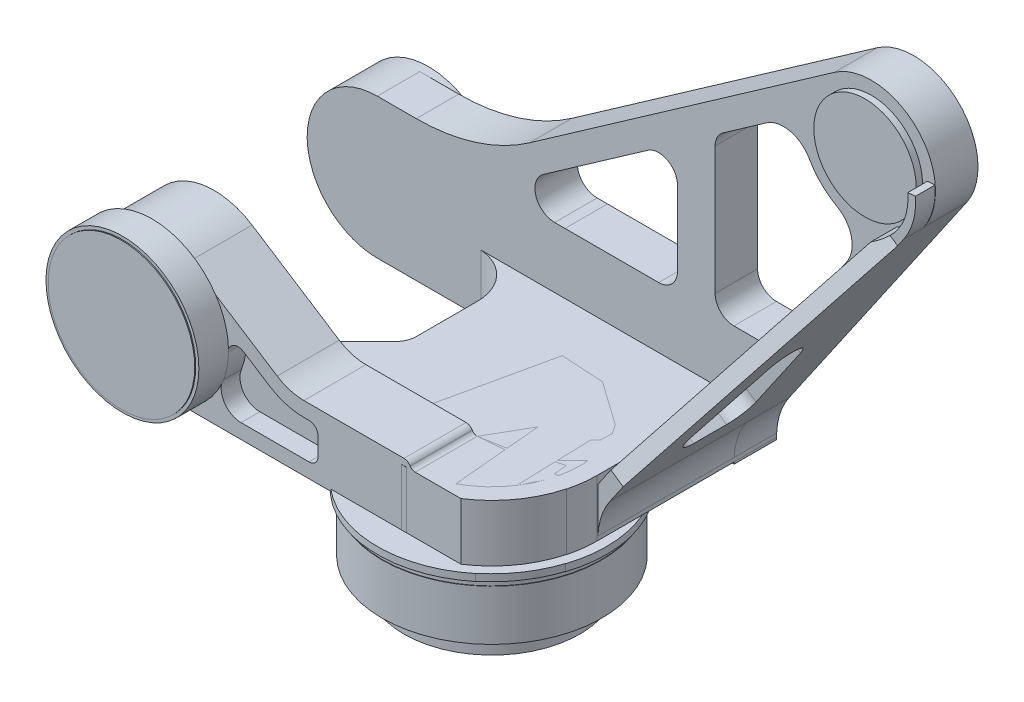
from build123d import *

# Parameters (mm, degrees)
SKETCH3_R               = 80.137
EXTRUDE1_DEPTH          = 6.5
SKETCH4_R               = 79.375
EXTRUDE2_DEPTH          = 13.5
SKETCH5_R               = 88.011
EXTRUDE3_DEPTH          = 5
SKETCH6_R               = 111.252
EXTRUDE4_DEPTH          = 51
SKETCH7_R               = 110.744
EXTRUDE5_DEPTH          = 7
SKETCH8_R               = 115.824
EXTRUDE6_DEPTH          = 7
EXTRUDE7_DEPTH          = 62.838001
CUT_EXTRUDE1_DEPTH      = 57.530765
CUT_EXTRUDE2_DEPTH      = 12.7
CUT_EXTRUDE3_DEPTH      = 19.05
SKETCH18_R              = 77.380878
EXTRUDE13_DEPTH         = 29.999999
SKETCH19_R              = 74.205878
EXTRUDE14_DEPTH         = 1
EXTRUDE15_DEPTH         = 57.530765
EXTRUDE17_START         = -43
EXTRUDE17_DEPTH         = 43
CUT_EXTRUDE4_DEPTH      = 43
EXTRUDE18_DEPTH         = 8.83485
EXTRUDE19_DEPTH         = 137.9365
CUT_EXTRUDE8_DEPTH      = 25.4
CUT_EXTRUDE8_DEPTH_BACK = 25.4
CUT_EXTRUDE9_DEPTH      = 247.851187
SKETCH34_R              = 56.999996
CUT_EXTRUDE10_DEPTH     = 101.6
SKETCH35_R              = 51.839563
EXTRUDE25_DEPTH         = 6.35
SKETCH40_R              = 89.151471
BOSS_EXTRUDE1_DEPTH     = 147.530765


with BuildPart() as part:
    # Sketch3 → Extrude1 (new body)
    with BuildSketch(Plane(origin=(0, 0, 0), x_dir=(1, 0, 0), z_dir=(0, 1, 0))):
        Circle(SKETCH3_R)
    extrude(amount=EXTRUDE1_DEPTH)

    # Sketch4 → Extrude2 (add)
    with BuildSketch(Plane(origin=(0, 6.5, 0), x_dir=(-1, 0, 0), z_dir=(0, 1, 0))):
        Circle(SKETCH4_R)
    extrude(amount=EXTRUDE2_DEPTH)

    # Sketch5 → Extrude3 (add)
    with BuildSketch(Plane(origin=(0, 20, 0), x_dir=(-1, 0, 0), z_dir=(0, 1, 0))):
        Circle(SKETCH5_R)
    extrude(amount=EXTRUDE3_DEPTH)

    # Sketch6 → Extrude4 (add)
    with BuildSketch(Plane(origin=(0, 25, 0), x_dir=(-1, 0, 0), z_dir=(0, 1, 0))):
        Circle(SKETCH6_R)
    extrude(amount=EXTRUDE4_DEPTH)

    # Sketch7 → Extrude5 (add)
    with BuildSketch(Plane(origin=(0, 76, 0), x_dir=(-1, 0, 0), z_dir=(0, 1, 0))):
        Circle(SKETCH7_R)
    extrude(amount=EXTRUDE5_DEPTH)

    # Sketch8 → Extrude6 (add)
    with BuildSketch(Plane(origin=(0, 83, 0), x_dir=(-1, 0, 0), z_dir=(0, 1, 0))):
        Circle(SKETCH8_R)
    extrude(amount=EXTRUDE6_DEPTH)

    # Sketch9 → Extrude7 (add)
    with BuildSketch(Plane.XY.offset(26.162)):
        with BuildLine():
            Line((-216.5859, 218.710663), (-128.357832, 161.950255))
            ThreePointArc((-128.357832, 161.950255), (-115.403783, 156.02872), (-101.30569, 153.999998))
            Line((-101.30569, 153.999998), (0, 153.999998))
            ThreePointArc((0, 153.999998), (3.562707, 152.95739), (6.222045, 150.367441))
            ThreePointArc((6.222045, 150.367441), (8.401692, 148.287721), (11.317701, 147.530765))
            Line((11.317701, 147.530765), (100.774792, 147.530765))
            Line((100.774792, 147.530765), (105.16392, 147.530765))
            Line((105.16392, 147.530765), (105.16392, 114.26347))
            Line((105.16392, 114.26347), (105.16392, 87.999945))
            Line((105.16392, 87.999945), (91.075027, 87.999945))
            Line((91.075027, 87.999945), (-255.000001, 87.999945))
            ThreePointArc((-255.000001, 87.999945), (-323.119262, 179.019319), (-216.5859, 218.710663))
        make_face()
    extrude(amount=EXTRUDE7_DEPTH)

    # Sketch10 → Cut-Extrude1 (cut)
    with BuildSketch(Plane(origin=(0, 147.530765, 0), x_dir=(-1, 0, 0), z_dir=(0, 1, 0))):
        with BuildLine():
            Line((-106.000005, 0), (-149.912166, 0))
            ThreePointArc((-149.912166, 0), (-141.516605, 49.46421), (-117.270277, 93.388113))
            Line((-117.270277, 93.388113), (-50.146405, 93.388113))
            ThreePointArc((-50.146405, 93.388113), (-90.971206, 54.408098), (-106.000005, 0))
        make_face()
    extrude(amount=-CUT_EXTRUDE1_DEPTH, mode=Mode.SUBTRACT)

    # Sketch11 → Cut-Extrude2 (cut)
    with BuildSketch(Plane(origin=(0, 90, 0), x_dir=(-1, 0, 0), z_dir=(0, 1, 0))):
        with BuildLine():
            Line((-110.220052, 34.625814), (-110.220052, 89.813505))
            Line((-110.220052, 89.813505), (-72.670084, 89.813505))
            ThreePointArc((-72.670084, 89.813505), (-95.517646, 64.990661), (-110.220052, 34.625814))
        make_face()
    extrude(amount=-CUT_EXTRUDE2_DEPTH, mode=Mode.SUBTRACT)

    # Sketch17 → Cut-Extrude3 (cut)
    with BuildSketch(Plane.XY.offset(89.000001)):
        with BuildLine():
            Line((-96.078082, 139.18), (-101.305787, 139.180008))
            ThreePointArc((-101.305787, 139.180008), (-119.582503, 141.810053), (-136.376086, 149.486711))
            Line((-136.376086, 149.486711), (-162.501405, 166.294086))
            ThreePointArc((-162.501405, 166.294086), (-172.82063, 166.703975), (-178.188143, 157.881038))
            ThreePointArc((-178.188143, 157.881038), (-179.671826, 143.934154), (-183.66653, 130.489481))
            ThreePointArc((-183.66653, 130.489481), (-181.636631, 111.684198), (-164.927799, 102.819995))
            Line((-164.927799, 102.819995), (-96.07809, 102.82))
            ThreePointArc((-96.07809, 102.82), (-89.691723, 105.46532), (-87.046404, 111.851687))
            Line((-87.046404, 111.851687), (-87.046404, 129.473045))
            ThreePointArc((-87.046404, 129.473045), (-89.448679, 136.293054), (-96.078082, 139.18))
        make_face()
    extrude(amount=-CUT_EXTRUDE3_DEPTH, mode=Mode.SUBTRACT)

    # Sketch18 → Extrude13 (add)
    with BuildSketch(Plane.XY.offset(89.000001)):
        with Locations((-255.000001, 158.999995)):
            Circle(SKETCH18_R)
    extrude(amount=EXTRUDE13_DEPTH)

    # Sketch19 → Extrude14 (add)
    with BuildSketch(Plane.XY.offset(119)):
        with Locations((-255.000001, 158.999995)):
            Circle(SKETCH19_R)
    extrude(amount=EXTRUDE14_DEPTH)

    # Sketch20 → Extrude15 (add)
    with BuildSketch(Plane(origin=(0, 90, 0), x_dir=(-1, 0, 0), z_dir=(0, 1, 0))):
        with BuildLine():
            Line((160.1168, 26.999999), (-102.720744, 26.999999))
            ThreePointArc((-102.720744, 26.999999), (-105.334028, 13.61226), (-106.209939, 0))
            Line((-106.209939, 0), (-106.209939, -182))
            Line((-106.209939, -182), (326.000001, -182))
            Line((326.000001, -182), (326.000001, -139))
            Line((326.000001, -139), (157.000002, -139))
            ThreePointArc((157.000002, -139), (121.874844, -126.667418), (107, -92.54106))
            Line((107, -92.54106), (107, -28.963737))
            ThreePointArc((107, -28.963737), (108.77282, -22.024733), (112.85787, -16.14213))
            Line((112.85787, -16.14213), (150.14213, 21.14214))
            ThreePointArc((150.14213, 21.14214), (154.754899, 24.708875), (160.1168, 26.999999))
        make_face()
    extrude(amount=EXTRUDE15_DEPTH)

    # Sketch21 → Extrude17 (add)
    with BuildSketch(Plane(origin=(0, 0, -182), x_dir=(-1, 0, 0), z_dir=(0, 0, -1)).offset(EXTRUDE17_START)):
        with BuildLine():
            Line((-298.533923, 392.133755), (-118.528, 130.7451))
            ThreePointArc((-118.528, 130.7451), (-108.8925, 110.374376), (-106.20994, 87.99999))
            Line((-106.20994, 87.99999), (255, 87.99999))
            ThreePointArc((255, 87.99999), (326.000006, 158.999994), (255.000001, 230))
            Line((255.000001, 230), (215.58525, 230))
            ThreePointArc((215.58525, 230), (155.444089, 239.25661), (100.869961, 266.169592))
            Line((100.869961, 266.169592), (-207.717556, 482.244896))
            ThreePointArc((-207.717556, 482.244896), (-290.78245, 475.140749), (-298.533923, 392.133755))
        make_face()
        with BuildLine():
            Line((-138.905945, 403.543127), (-95.020224, 372.814011))
            ThreePointArc((-95.020224, 372.814011), (-89.049299, 366.005476), (-86.896855, 357.209165))
            Line((-86.896855, 357.209165), (-86.896855, 228.05001))
            ThreePointArc((-86.896855, 228.05001), (-92.476472, 214.579625), (-105.946857, 209.00001))
            Line((-105.946857, 209.00001), (-131.553208, 209.000011))
            ThreePointArc((-131.553208, 209.000011), (-140.857258, 211.295926), (-148.025176, 217.656547))
            Line((-148.025176, 217.656547), (-220.370986, 322.710727))
            ThreePointArc((-220.370986, 322.710727), (-224.863225, 346.606927), (-210.173896, 365.982999))
            ThreePointArc((-210.173896, 365.982999), (-194.287144, 377.890255), (-182.256404, 393.683701))
            ThreePointArc((-182.256404, 393.683701), (-162.766399, 408.221526), (-138.905945, 403.543127))
        make_face(mode=Mode.SUBTRACT)
        with BuildLine():
            Line((-48.796855, 303.853353), (-48.796855, 228.050005))
            ThreePointArc((-48.796855, 228.050005), (-43.21724, 214.579621), (-29.746857, 209.000005))
            Line((-29.746857, 209.000005), (65, 208.999999))
            Line((65, 208.999999), (75.49853, 208.999999))
            ThreePointArc((75.49853, 208.999999), (94.572868, 222.985883), (86.97006, 245.383039))
            Line((86.97006, 245.383039), (-18.820224, 319.458199))
            ThreePointArc((-18.820224, 319.458199), (-38.543166, 320.750909), (-48.796855, 303.853353))
        make_face(mode=Mode.SUBTRACT)
    extrude(amount=EXTRUDE17_DEPTH)

    # Sketch22 → Cut-Extrude4 (cut)
    with BuildSketch(Plane(origin=(0, 0, -182), x_dir=(-1, 0, 0), z_dir=(0, 0, -1))):
        with BuildLine():
            Line((255.000001, 230), (339.549751, 230))
            Line((339.549751, 230), (339.549751, 79.674869))
            Line((339.549751, 79.674869), (255, 79.674869))
            Line((255, 79.674869), (255, 87.99999))
            ThreePointArc((255, 87.99999), (326.000006, 158.999994), (255.000001, 230))
        make_face()
    extrude(amount=-CUT_EXTRUDE4_DEPTH, mode=Mode.SUBTRACT)

    # Sketch23 → Extrude18 (add)
    with BuildSketch(Plane(origin=(0, 0, -182), x_dir=(-1, 0, 0), z_dir=(0, 0, -1))):
        with BuildLine():
            ThreePointArc((255, 87.99999), (326.000006, 158.999994), (255.000001, 230))
            ThreePointArc((255.000001, 230), (183.999996, 158.999995), (255, 87.99999))
        make_face()
    extrude(amount=EXTRUDE18_DEPTH)

    # Sketch26 → Extrude19 (add)
    with BuildSketch(Plane.XY.offset(-139)):
        with BuildLine():
            Line((297.780353, 391.039487), (118.528, 130.7451))
            ThreePointArc((118.528, 130.7451), (109.766215, 113.183583), (106.209939, 93.882582))
            Line((106.209939, 93.882582), (106.181792, 139.263981))
            Line((106.181792, 139.263981), (286.179939, 400.641357))
            ThreePointArc((286.179939, 400.641357), (293.326239, 416.171316), (294.823217, 433.200946))
            Line((294.823217, 433.200946), (309.571556, 434.444482))
            ThreePointArc((309.571556, 434.444482), (307.376936, 411.736593), (297.780353, 391.039487))
        make_face()
    extrude(amount=EXTRUDE19_DEPTH)

    # Sketch27 → Cut-Extrude8 (cut, two sides)
    with BuildSketch(Plane(origin=(6.971258, -4.800774, 0), x_dir=(0, 0, 1), z_dir=(-0.823599, 0.567173, 0))) as cut_extrude8_sk:
        Polygon((-0.861977, 197.72796), (-119.141703, 479.888191), (-119.141703, 538.066737), (6.897193, 541.881723), (6.897193, 195.671685), align=None)
    extrude(amount=CUT_EXTRUDE8_DEPTH, mode=Mode.SUBTRACT)
    extrude(cut_extrude8_sk.sketch, amount=-CUT_EXTRUDE8_DEPTH_BACK, mode=Mode.SUBTRACT)

    # Sketch28 → Cut-Extrude9 (cut, through all)
    with BuildSketch(Plane(origin=(6.971258, -4.800774, 0), x_dir=(0, 0, 1), z_dir=(-0.823599, 0.567173, 0))):
        with BuildLine():
            Line((-50.131329, 233.135437), (-83.331186, 312.334802))
            ThreePointArc((-83.331186, 312.334802), (-104.656101, 323.646103), (-119.95, 304.97007))
            Line((-119.95, 304.97007), (-119.95, 225.770705))
            ThreePointArc((-119.95, 225.770705), (-114.370384, 212.300321), (-100.9, 206.720705))
            Line((-100.9, 206.720705), (-67.700143, 206.720705))
            ThreePointArc((-67.700143, 206.720705), (-51.838229, 215.22072), (-50.131329, 233.135437))
        make_face()
    extrude(amount=-CUT_EXTRUDE9_DEPTH, mode=Mode.SUBTRACT)

    # Sketch34 → Cut-Extrude10 (cut)
    with BuildSketch(Plane.XY.offset(-139)):
        with Locations((245.000012, 429.000011)):
            Circle(SKETCH34_R)
    extrude(amount=CUT_EXTRUDE10_DEPTH, mode=Mode.SUBTRACT)

    # Sketch35 → Extrude25 (add)
    with BuildSketch(Plane.XY.offset(-139)):
        with Locations((245.000012, 429.000011)):
            Circle(SKETCH35_R)
    extrude(amount=EXTRUDE25_DEPTH)


with BuildPart() as body_2:
    # Sketch40 → Boss-Extrude1 (new body)
    with BuildSketch(Plane(origin=(0, 147.530765, 0), x_dir=(1, 0, 0), z_dir=(0, 1, 0))):
        Circle(SKETCH40_R)
    extrude(amount=-BOSS_EXTRUDE1_DEPTH)


solid = Compound([part.part, body_2.part])
